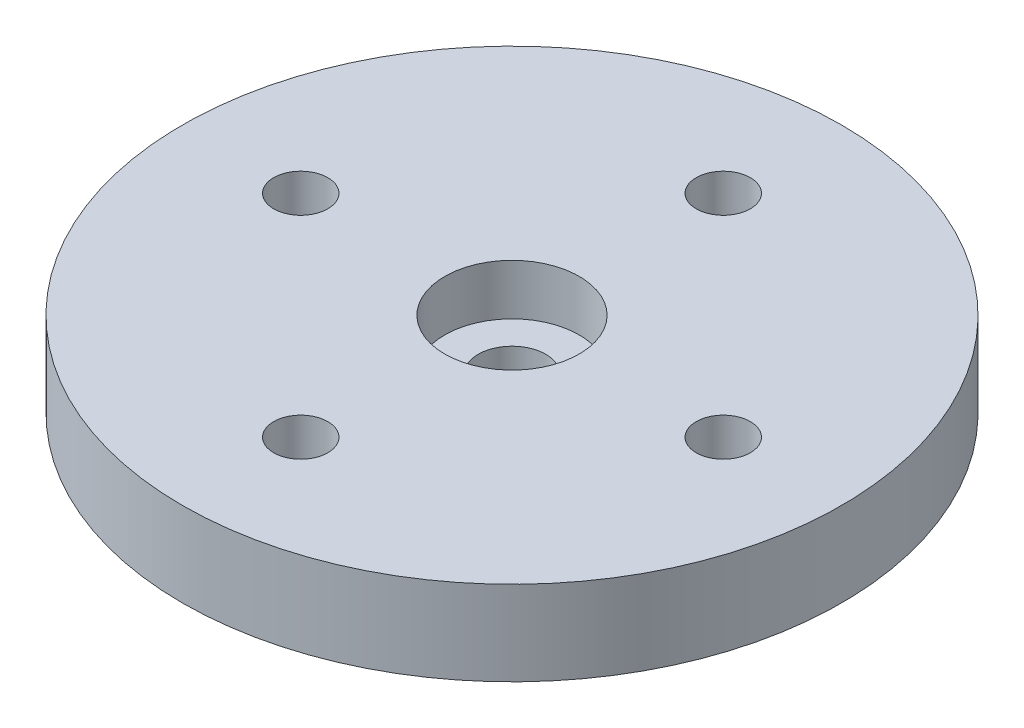
from build123d import *

# Parameters (mm, degrees)
SKETCH1_R           = 19.5
BOSS_EXTRUDE1_DEPTH = 5
SKETCH2_R           = 3.98
CUT_EXTRUDE1_DEPTH  = 3
SKETCH3_R           = 2
CUT_EXTRUDE2_DEPTH  = 3
SKETCH4_R           = 1.6
CUT_EXTRUDE3_DEPTH  = 6
CIRPATTERN1_COUNT   = 4


with BuildPart() as part:
    # Sketch1 → Boss-Extrude1 (new body)
    with BuildSketch(Plane(origin=(0, 0, 0), x_dir=(1, 0, 0), z_dir=(0, 1, 0))):
        Circle(SKETCH1_R)
    extrude(amount=BOSS_EXTRUDE1_DEPTH)

    # Sketch2 → Cut-Extrude1 (cut)
    with BuildSketch(Plane(origin=(0, 5, 0), x_dir=(1, 0, 0), z_dir=(0, 1, 0))):
        Circle(SKETCH2_R)
    extrude(amount=-CUT_EXTRUDE1_DEPTH, mode=Mode.SUBTRACT)

    # Sketch3 → Cut-Extrude2 (cut)
    with BuildSketch(Plane(origin=(0, 2, 0), x_dir=(1, 0, 0), z_dir=(0, 1, 0))):
        Circle(SKETCH3_R)
    extrude(amount=-CUT_EXTRUDE2_DEPTH, mode=Mode.SUBTRACT)

    # Sketch4 → Cut-Extrude3 (cut, through all)
    with BuildSketch(Plane(origin=(0, 5, 0), x_dir=(1, 0, 0), z_dir=(0, 1, 0))):
        with Locations((0, 12.5)):
            Circle(SKETCH4_R)
    cut_extrude3 = extrude(amount=-CUT_EXTRUDE3_DEPTH, mode=Mode.SUBTRACT)

    # CirPattern1: Cut-Extrude3 ×4 about axis
    cirpattern1_axis = Axis((0, 0, 0), (0, 1, 0))
    for i in range(1, CIRPATTERN1_COUNT):
        add(cut_extrude3.rotate(cirpattern1_axis, i * 360 / CIRPATTERN1_COUNT), mode=Mode.SUBTRACT)


solid = part.part
